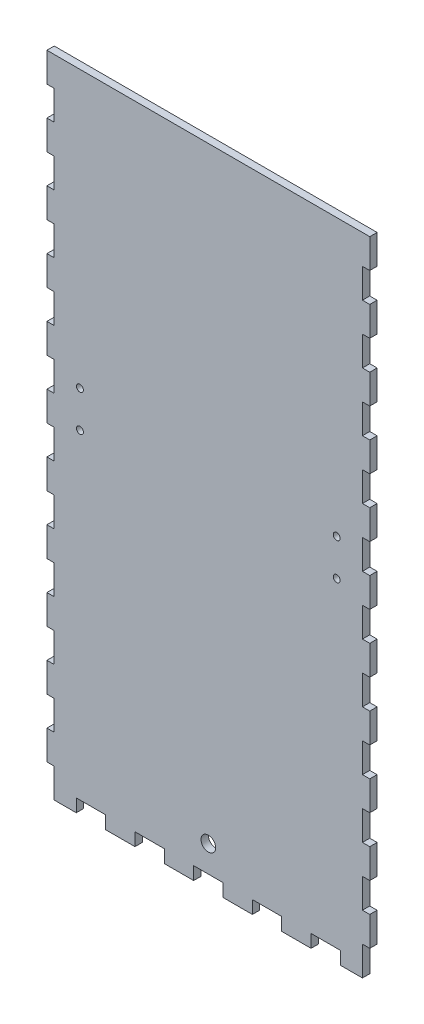
from build123d import *

# Parameters (mm, degrees)
SKETCH1_W           = 3.175
SKETCH1_H           = 12.7
SKETCH1_W_2         = 9.525
SKETCH1_H_2         = 5.588
SKETCH1_W_3         = 12.7
BOSS_EXTRUDE1_DEPTH = 3.175
SKETCH2_R           = 3.175
CUT_EXTRUDE1_DEPTH  = 4.175
SKETCH3_R           = 1.5
CUT_EXTRUDE2_DEPTH  = 4.175


with BuildPart() as part:
    # Sketch1 → Boss-Extrude1 (new body)
    with BuildSketch(Plane.XY):
        Polygon((-66.675, 273.812), (-66.675, 261.112), (-66.675, 248.412), (-66.675, 235.712), (-66.675, 223.012), (-66.675, 210.312), (-66.675, 197.612), (-66.675, 184.912), (-66.675, 172.212), (-66.675, 159.512), (-66.675, 146.812), (-66.675, 134.112), (-66.675, 121.412), (-66.675, 108.712), (-66.675, 96.012), (-66.675, 83.312), (-66.675, 70.612), (-66.675, 57.912), (-66.675, 45.212), (-66.675, 32.512), (-66.675, 19.812), (-66.675, 7.112), (-66.675, 0), (-57.15, 0), (-44.45, 0), (-31.75, 0), (-19.05, 0), (-6.35, 0), (6.35, 0), (19.05, 0), (31.75, 0), (44.45, 0), (57.15, 0), (66.675, 0), (66.675, 7.112), (66.675, 19.812), (66.675, 32.512), (66.675, 45.212), (66.675, 57.912), (66.675, 70.612), (66.675, 83.312), (66.675, 96.012), (66.675, 108.712), (66.675, 121.412), (66.675, 134.112), (66.675, 146.812), (66.675, 159.512), (66.675, 172.212), (66.675, 184.912), (66.675, 197.612), (66.675, 210.312), (66.675, 223.012), (66.675, 235.712), (66.675, 248.412), (66.675, 261.112), (66.675, 273.812), align=None)
        with Locations((-68.2625, 13.462)):
            Rectangle(SKETCH1_W, SKETCH1_H)
        with Locations((-68.2625, 38.862)):
            Rectangle(SKETCH1_W, SKETCH1_H)
        with Locations((-68.2625, 64.262)):
            Rectangle(SKETCH1_W, SKETCH1_H)
        with Locations((-68.2625, 89.662)):
            Rectangle(SKETCH1_W, SKETCH1_H)
        with Locations((-61.9125, -2.794)):
            Rectangle(SKETCH1_W_2, SKETCH1_H_2)
        with Locations((-38.1, -2.794)):
            Rectangle(SKETCH1_W_3, SKETCH1_H_2)
        with Locations((-12.7, -2.794)):
            Rectangle(SKETCH1_W_3, SKETCH1_H_2)
        with Locations((12.7, -2.794)):
            Rectangle(SKETCH1_W_3, SKETCH1_H_2)
        with Locations((38.1, -2.794)):
            Rectangle(SKETCH1_W_3, SKETCH1_H_2)
        with Locations((61.9125, -2.794)):
            Rectangle(SKETCH1_W_2, SKETCH1_H_2)
        with Locations((68.2625, 13.462)):
            Rectangle(SKETCH1_W, SKETCH1_H)
        with Locations((68.2625, 38.862)):
            Rectangle(SKETCH1_W, SKETCH1_H)
        with Locations((68.2625, 64.262)):
            Rectangle(SKETCH1_W, SKETCH1_H)
        with Locations((68.2625, 89.662)):
            Rectangle(SKETCH1_W, SKETCH1_H)
        with Locations((68.2625, 115.062)):
            Rectangle(SKETCH1_W, SKETCH1_H)
        with Locations((-68.2625, 115.062)):
            Rectangle(SKETCH1_W, SKETCH1_H)
        with Locations((-68.2625, 140.462)):
            Rectangle(SKETCH1_W, SKETCH1_H)
        with Locations((-68.2625, 165.862)):
            Rectangle(SKETCH1_W, SKETCH1_H)
        with Locations((-68.2625, 191.262)):
            Rectangle(SKETCH1_W, SKETCH1_H)
        with Locations((-68.2625, 216.662)):
            Rectangle(SKETCH1_W, SKETCH1_H)
        with Locations((-68.2625, 242.062)):
            Rectangle(SKETCH1_W, SKETCH1_H)
        with Locations((-68.2625, 267.462)):
            Rectangle(SKETCH1_W, SKETCH1_H)
        with Locations((68.2625, 140.462)):
            Rectangle(SKETCH1_W, SKETCH1_H)
        with Locations((68.2625, 165.862)):
            Rectangle(SKETCH1_W, SKETCH1_H)
        with Locations((68.2625, 191.262)):
            Rectangle(SKETCH1_W, SKETCH1_H)
        with Locations((68.2625, 216.662)):
            Rectangle(SKETCH1_W, SKETCH1_H)
        with Locations((68.2625, 242.062)):
            Rectangle(SKETCH1_W, SKETCH1_H)
        with Locations((68.2625, 267.462)):
            Rectangle(SKETCH1_W, SKETCH1_H)
    extrude(amount=BOSS_EXTRUDE1_DEPTH)

    # Sketch2 → Cut-Extrude1 (cut, through all)
    with BuildSketch(Plane.XY.offset(3.175)):
        with Locations((0, 11.43)):
            Circle(SKETCH2_R)
    extrude(amount=-CUT_EXTRUDE1_DEPTH, mode=Mode.SUBTRACT)

    # Sketch3 → Cut-Extrude2 (cut, through all)
    with BuildSketch(Plane.XY.offset(3.175)):
        with Locations((-55.5625, 154.305)):
            Circle(SKETCH3_R)
        with Locations((-55.5625, 138.557)):
            Circle(SKETCH3_R)
        with Locations((55.5625, 154.305)):
            Circle(SKETCH3_R)
        with Locations((55.5625, 138.557)):
            Circle(SKETCH3_R)
    extrude(amount=-CUT_EXTRUDE2_DEPTH, mode=Mode.SUBTRACT)


solid = part.part
